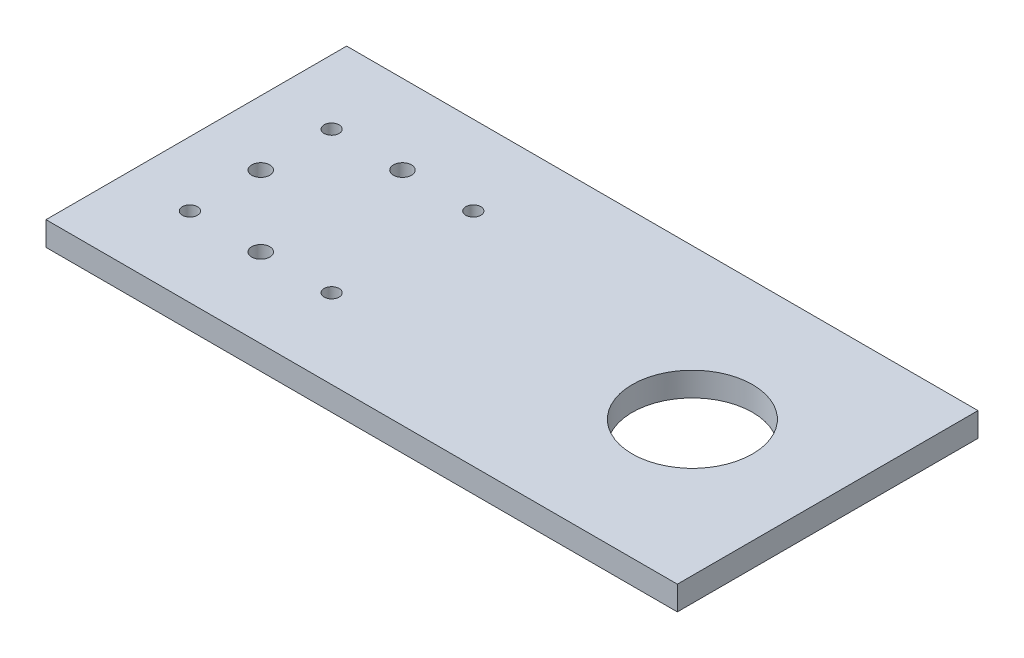
from build123d import *

# Parameters (mm, degrees)
SKETCH1_W           = 250
SKETCH1_H           = 100
BOSS_EXTRUDE1_DEPTH = 8
SKETCH2_R           = 2.5
CUT_EXTRUDE1_DEPTH  = 8
SKETCH3_R           = 3
CUT_EXTRUDE2_DEPTH  = 8
SKETCH5_W           = 40
SKETCH5_H           = 100
CUT_EXTRUDE3_DEPTH  = 10
SKETCH6_R           = 20
CUT_EXTRUDE4_DEPTH  = 8


with BuildPart() as part:
    # Sketch1 → Boss-Extrude1 (new body)
    with BuildSketch(Plane(origin=(0, 0, 0), x_dir=(1, 0, 0), z_dir=(0, 1, 0))):
        Rectangle(SKETCH1_W, SKETCH1_H)
    extrude(amount=BOSS_EXTRUDE1_DEPTH)

    # Sketch2 → Cut-Extrude1 (cut)
    with BuildSketch(Plane(origin=(0, 8, 0), x_dir=(1, 0, 0), z_dir=(0, 1, 0))):
        with Locations((-103.57, 23.57)):
            Circle(SKETCH2_R)
        with Locations((-56.43, 23.57)):
            Circle(SKETCH2_R)
        with Locations((-56.43, -23.57)):
            Circle(SKETCH2_R)
        with Locations((-103.57, -23.57)):
            Circle(SKETCH2_R)
    extrude(amount=-CUT_EXTRUDE1_DEPTH, mode=Mode.SUBTRACT)

    # Sketch3 → Cut-Extrude2 (cut)
    with BuildSketch(Plane(origin=(0, 8, 0), x_dir=(1, 0, 0), z_dir=(0, 1, 0))):
        with Locations((-80, 23.57)):
            Circle(SKETCH3_R)
        with Locations((-103.57, 0)):
            Circle(SKETCH3_R)
        with Locations((-80, -23.57)):
            Circle(SKETCH3_R)
    extrude(amount=-CUT_EXTRUDE2_DEPTH, mode=Mode.SUBTRACT)

    # Sketch5 → Cut-Extrude3 (cut)
    with BuildSketch(Plane.XZ):
        with Locations((105, 0)):
            Rectangle(SKETCH5_W, SKETCH5_H)
    extrude(amount=-CUT_EXTRUDE3_DEPTH, mode=Mode.SUBTRACT)

    # Sketch6 → Cut-Extrude4 (cut)
    with BuildSketch(Plane.XZ):
        with Locations((40, 0)):
            Circle(SKETCH6_R)
    extrude(amount=-CUT_EXTRUDE4_DEPTH, mode=Mode.SUBTRACT)


solid = part.part
